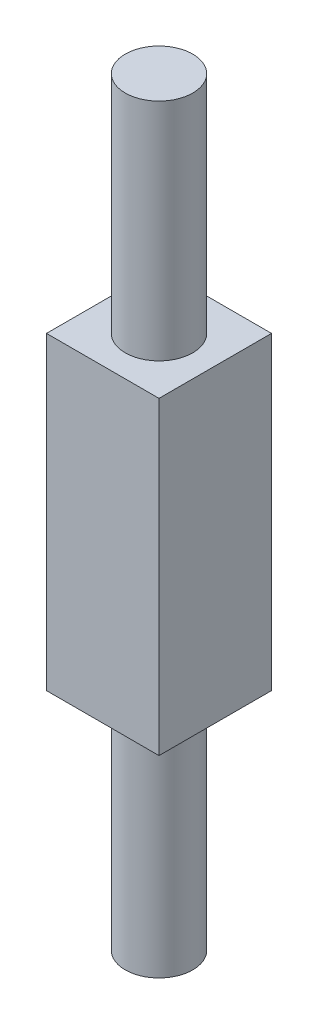
from build123d import *

# Parameters (mm, degrees)
SKETCH1_R           = 1.2
BOSS_EXTRUDE1_DEPTH = 13.5
SKETCH2_W           = 4
SKETCH2_H           = 4
BOSS_EXTRUDE2_DEPTH = 5.5


with BuildPart() as part:
    # Sketch1 → Boss-Extrude1 (new body, symmetric)
    with BuildSketch(Plane(origin=(0, 0, 0), x_dir=(1, 0, 0), z_dir=(0, 1, 0))):
        Circle(SKETCH1_R)
    extrude(amount=BOSS_EXTRUDE1_DEPTH, both=True)

    # Sketch2 → Boss-Extrude2 (add, symmetric)
    with BuildSketch(Plane(origin=(0, 0, 0), x_dir=(1, 0, 0), z_dir=(0, 1, 0))):
        Rectangle(SKETCH2_W, SKETCH2_H)
    extrude(amount=BOSS_EXTRUDE2_DEPTH, both=True)


solid = part.part
